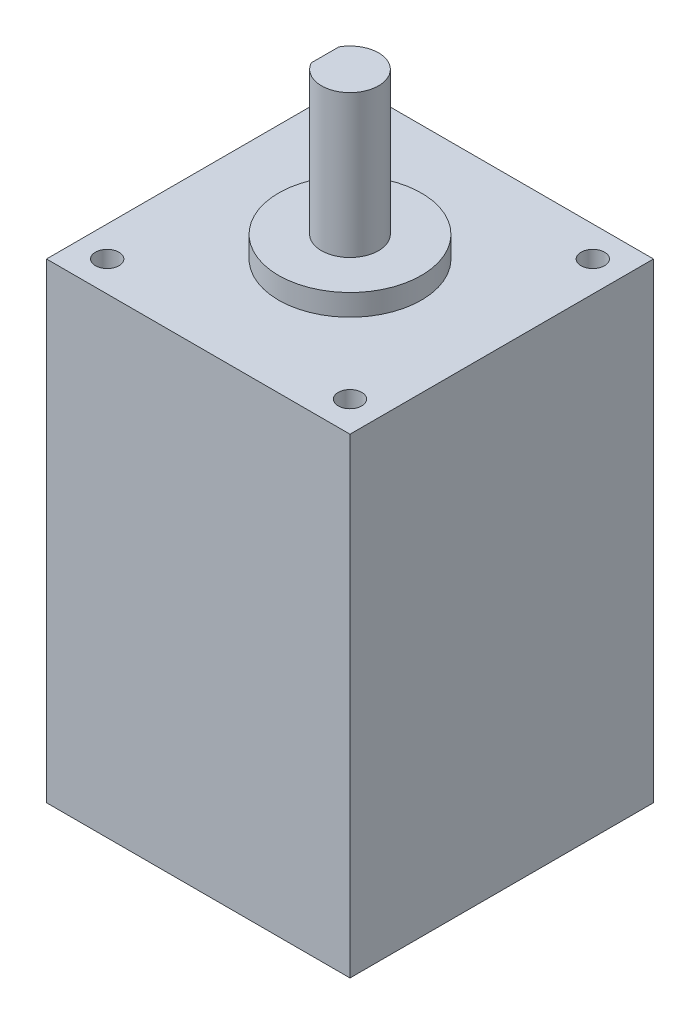
from build123d import *

# Parameters (mm, degrees)
SKETCH_1_W          = 42.5
SKETCH_1_H          = 42.5
EXTRUDE_1_DEPTH     = 65.95
SKETCH_2_R          = 10
EXTRUDE_2_DEPTH     = 3
SKETCH_3_R          = 4
EXTRUDE_3_DEPTH     = 20
HOLE_WIZARD_3_D     = 3.3
HOLE_WIZARD_3_DEPTH = 11.5
HOLE_WIZARD_3_TIP   = 0.991420021
EXTRUDE_4_DEPTH     = 12


with BuildPart() as part:
    # 스케치1 → 돌출1 (new body)
    with BuildSketch(Plane(origin=(0, 0, 0), x_dir=(-1, 0, 0), z_dir=(0, 1, 0))):
        with Locations((21.25, -21.25)):
            Rectangle(SKETCH_1_W, SKETCH_1_H)
    extrude(amount=EXTRUDE_1_DEPTH)

    # 스케치2 → 돌출2 (add)
    with BuildSketch(Plane(origin=(0, 65.95, 0), x_dir=(-1, 0, 0), z_dir=(0, 1, 0))):
        with Locations((21.25, -21.25)):
            Circle(SKETCH_2_R)
    extrude(amount=EXTRUDE_2_DEPTH)

    # 스케치3 → 돌출3 (add)
    with BuildSketch(Plane(origin=(0, 68.95, 0), x_dir=(-1, 0, 0), z_dir=(0, 1, 0))):
        with Locations((21.25, -21.25)):
            Circle(SKETCH_3_R)
    extrude(amount=EXTRUDE_3_DEPTH)

    # 구멍3
    with Locations(Plane(origin=(0, 65.95, 0), x_dir=(1, 0, 0), z_dir=(0, 1, 0))):
        with Locations((-4.25, 38.25), (-4.25, 4.25), (-38.25, 4.25), (-38.25, 38.25)):
            Hole(HOLE_WIZARD_3_D / 2, depth=HOLE_WIZARD_3_DEPTH)
            with Locations((0, 0, -(HOLE_WIZARD_3_DEPTH + HOLE_WIZARD_3_TIP / 2))):  # 118° drill point
                Cone(0, HOLE_WIZARD_3_D / 2, HOLE_WIZARD_3_TIP, mode=Mode.SUBTRACT)

    # 스케치6 → 돌출4 (cut)
    with BuildSketch(Plane(origin=(0, 88.95, 0), x_dir=(-1, 0, 0), z_dir=(0, 1, 0))):
        with BuildLine():
            Line((24.75, -19.313508327), (24.75, -23.186491673))
            ThreePointArc((24.75, -23.186491673), (25.25, -21.25), (24.75, -19.313508327))
        make_face()
    extrude(amount=-EXTRUDE_4_DEPTH, mode=Mode.SUBTRACT)


solid = part.part
